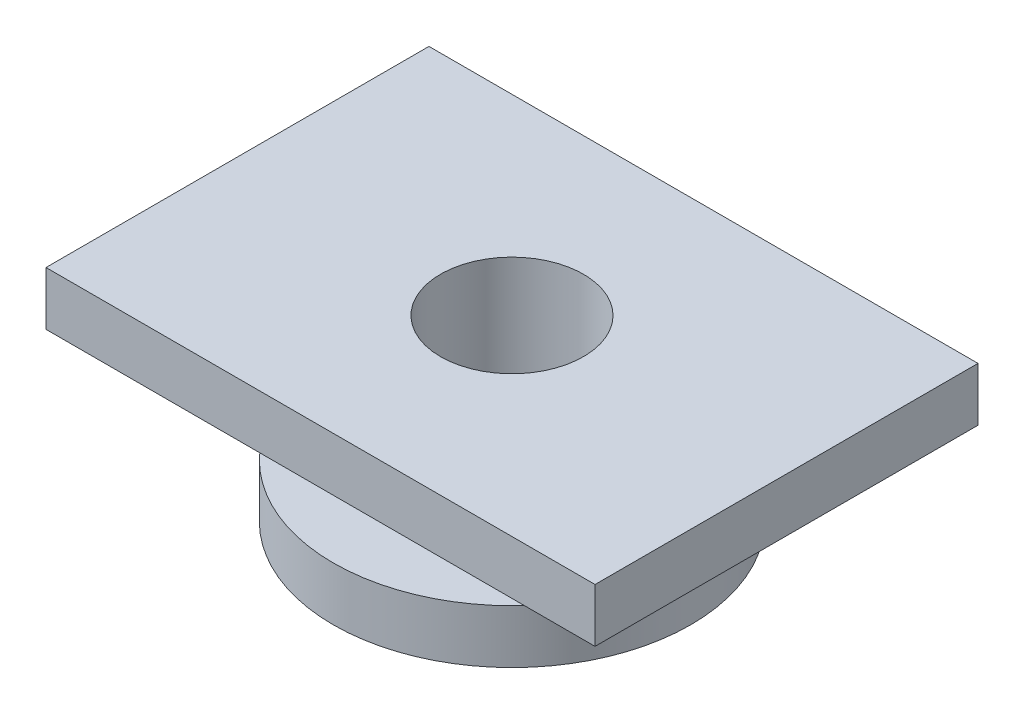
from build123d import *

# Parameters (mm, degrees)
SKETCH1_R           = 10
SKETCH1_R_2         = 4
BOSS_EXTRUDE1_DEPTH = 1.5
SKETCH2_R           = 6
SKETCH2_R_2         = 4
BOSS_EXTRUDE2_DEPTH = 4
SKETCH3_W           = 30.73076969
SKETCH3_H           = 21.435526278
SKETCH3_R           = 4
BOSS_EXTRUDE3_DEPTH = 3


with BuildPart() as part:
    # Sketch1 → Boss-Extrude1 (new body, symmetric)
    with BuildSketch(Plane(origin=(0, 0, 0), x_dir=(1, 0, 0), z_dir=(0, 1, 0))):
        Circle(SKETCH1_R)
        Circle(SKETCH1_R_2, mode=Mode.SUBTRACT)
    extrude(amount=BOSS_EXTRUDE1_DEPTH, both=True)

    # Sketch2 → Boss-Extrude2 (add)
    with BuildSketch(Plane(origin=(0, 1.5, 0), x_dir=(1, 0, 0), z_dir=(0, 1, 0))):
        Circle(SKETCH2_R)
        Circle(SKETCH2_R_2, mode=Mode.SUBTRACT)
    extrude(amount=BOSS_EXTRUDE2_DEPTH)

    # Sketch3 → Boss-Extrude3 (add)
    with BuildSketch(Plane(origin=(0, 5.5, 0), x_dir=(1, 0, 0), z_dir=(0, 1, 0))):
        Rectangle(SKETCH3_W, SKETCH3_H)
        Circle(SKETCH3_R, mode=Mode.SUBTRACT)
    extrude(amount=BOSS_EXTRUDE3_DEPTH)


solid = part.part
